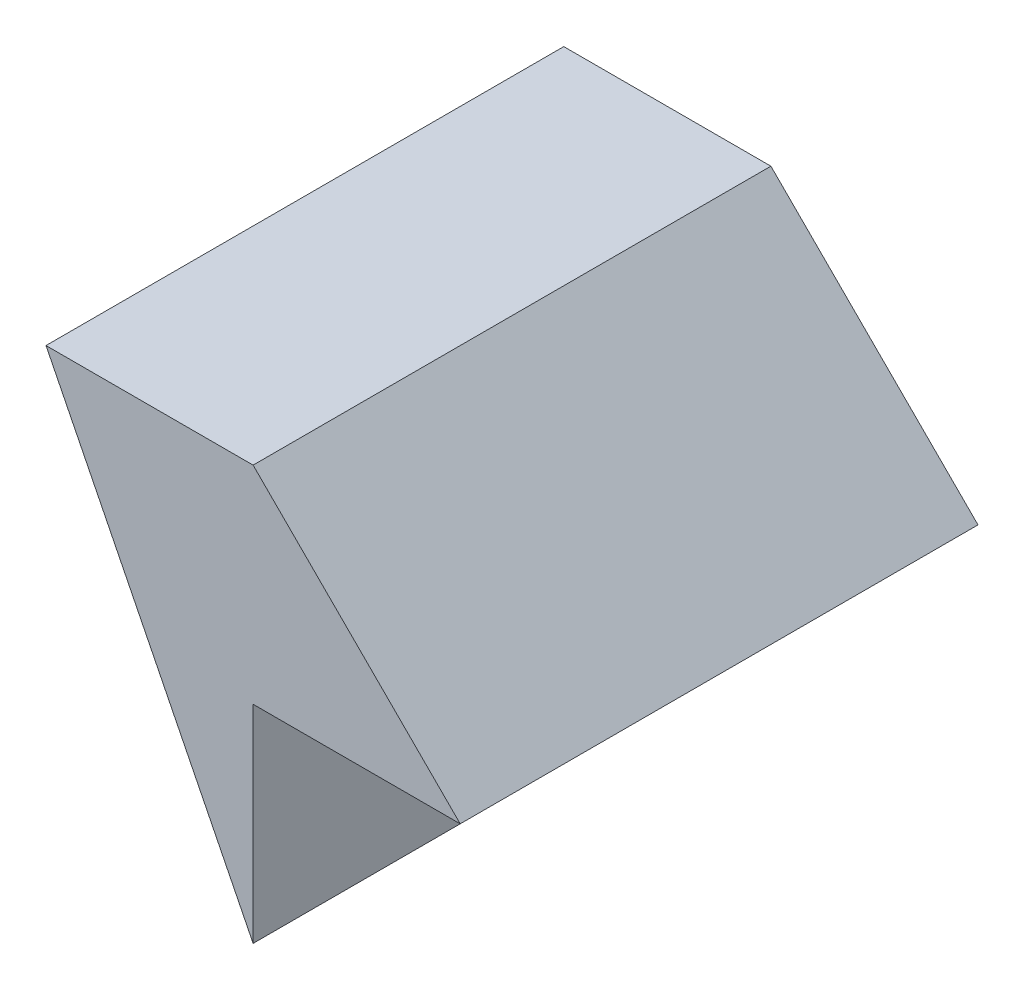
from build123d import *

# Parameters (mm, degrees)
BOSS_EXTRUDE1_DEPTH = 25


with BuildPart() as part:
    # Sketch1 → Boss-Extrude1 (new body)
    with BuildSketch(Plane.XY):
        Polygon((-10, 10), (0, 10), (10, 0), (0, 0), (0, -10), align=None)
    extrude(amount=BOSS_EXTRUDE1_DEPTH)


solid = part.part
